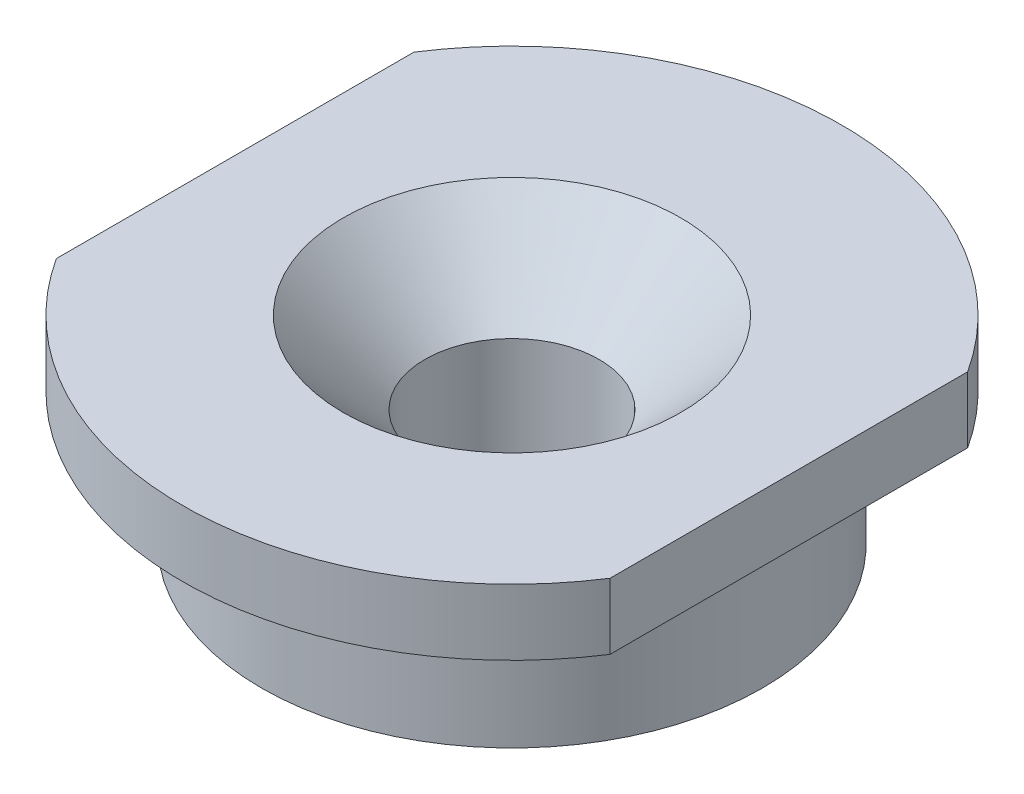
from build123d import *

# Parameters (mm, degrees)
HOLE_WIZARD_1_D           = 6.6
HOLE_WIZARD_1_CSINK_D     = 12.8
HOLE_WIZARD_1_CSINK_ANGLE = 90
SKETCH_3_W                = 2
SKETCH_3_H                = 2.5
CUT_EXTRUDE_1_DEPTH       = 13.5
CUT_EXTRUDE_1_DEPTH_BACK  = 13.5


with BuildPart() as part:
    # 草图1 → 旋转1 (revolve)
    with BuildSketch(Plane.XY):
        Polygon((0, 0), (9.5, 0), (9.5, 5), (12.5, 5), (12.5, 7.5), (0, 7.5), align=None)
    revolve(axis=Axis((0, 11.114035088, 0), (0, -1, 0)))

    # 打孔尺寸(%根据)内六角花形半沉头螺钉的类型1 (through all)
    with Locations(Plane.ZX.offset(7.5)):
        with Locations((0, 0)):
            CounterSinkHole(HOLE_WIZARD_1_D / 2, HOLE_WIZARD_1_CSINK_D / 2, counter_sink_angle=HOLE_WIZARD_1_CSINK_ANGLE)

    # 草图3 → 切除-拉伸1 (cut, two sides)
    with BuildSketch(Plane.XY) as cut_extrude_1_sk:
        with Locations((-11.5, 6.25)):
            Rectangle(SKETCH_3_W, SKETCH_3_H)
        with Locations((11.5, 6.25)):
            Rectangle(SKETCH_3_W, SKETCH_3_H)
    extrude(amount=CUT_EXTRUDE_1_DEPTH, mode=Mode.SUBTRACT)
    extrude(cut_extrude_1_sk.sketch, amount=-CUT_EXTRUDE_1_DEPTH_BACK, mode=Mode.SUBTRACT)


solid = part.part
